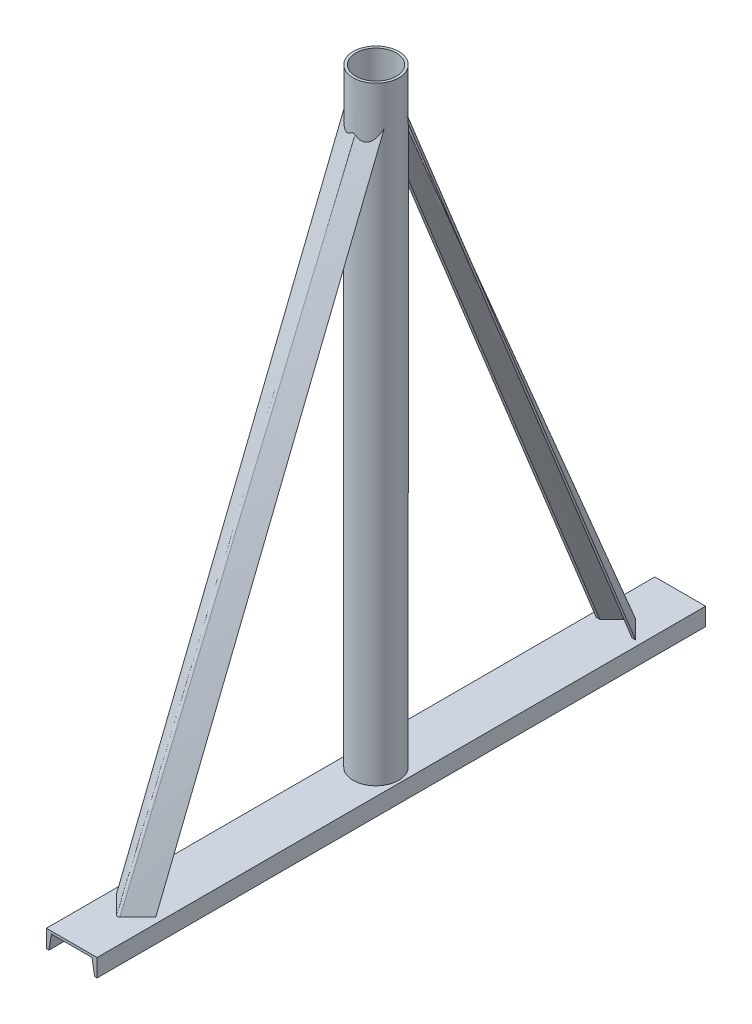
from build123d import *
from build123d.topology import SkipClean

# Parameters (mm, degrees)
BOSS_EXTRUDE1_DEPTH = 1524
SKETCH2_R           = 57.15
SKETCH2_R_2         = 50.8
BOSS_EXTRUDE2_DEPTH = 1524
SKETCH5_W           = 191.890592184
SKETCH5_H           = 1601.586805461
CUT_EXTRUDE1_DEPTH  = 826.77
SKETCH11_R          = 50.8
CUT_EXTRUDE3_DEPTH  = 826.77


with BuildPart() as part:
    # Sketch1 → Boss-Extrude1 (new body)
    with BuildSketch(Plane.XY):
        Polygon((63.5, 0), (-63.5, 0), (-63.5, -44.45), (-57.15, -44.45), (-50.8, -6.35), (50.8, -6.35), (57.15, -44.45), (63.5, -44.45), align=None)
    extrude(amount=BOSS_EXTRUDE1_DEPTH)

    # Sketch2 → Boss-Extrude2 (add)
    with BuildSketch(Plane(origin=(0, 0, 0), x_dir=(1, 0, 0), z_dir=(0, 1, 0))):
        with Locations(Location((0, -762, 0), (0, 0, 90))):
            Circle(SKETCH2_R)
        with Locations(Location((0, -762, 0), (0, 0, 270))):
            Circle(SKETCH2_R_2, mode=Mode.SUBTRACT)
    boss_extrude2 = extrude(amount=BOSS_EXTRUDE2_DEPTH)

    # Sketch5 → Cut-Extrude1 (cut)
    with BuildSketch(Plane.XY.offset(762)):
        with Locations((-8.264108144, 805.673812156)):
            Rectangle(SKETCH5_W, SKETCH5_H)
    extrude(amount=CUT_EXTRUDE1_DEPTH, mode=Mode.SUBTRACT)

    # Sketch8 for Loft6 → Loft6 section 0
    with BuildSketch(Plane.XY.offset(736.6)):
        with BuildLine():
            Line((4.490128061, 1477.690128061), (49.391408666, 1432.788847455))
            Line((49.391408666, 1432.788847455), (40.411152545, 1432.788847455))
            Line((40.411152545, 1432.788847455), (1.796051224, 1471.403948776))
            # circular arc as an exact rational Bezier (weights 1, cos(half-angle), 1)
            Bezier((1.796051224, 1471.403948776), (0, 1473.2), (-1.796051224, 1471.403948776), weights=[1, 0.707106781, 1])
            Line((-1.796051224, 1471.403948776), (-40.411152545, 1432.788847455))
            Line((-40.411152545, 1432.788847455), (-49.391408666, 1432.788847455))
            Line((-49.391408666, 1432.788847455), (-4.490128061, 1477.690128061))
            Bezier((-4.490128061, 1477.690128061), (0, 1482.180256121), (4.490128061, 1477.690128061), weights=[1, 0.707106781, 1])
        make_face()
    # Sketch4 for Loft6 → Loft6 section 1
    with BuildSketch(Plane(origin=(0, 0, 0), x_dir=(1, 0, 0), z_dir=(0, 1, 0))):
        with BuildLine():
            Line((4.490128061, -116.159871939), (49.391408666, -161.061152545))
            Line((49.391408666, -161.061152545), (40.411152545, -161.061152545))
            Line((40.411152545, -161.061152545), (1.796051224, -122.446051224))
            Bezier((1.796051224, -122.446051224), (0, -120.65), (-1.796051224, -122.446051224), weights=[1, 0.707106781, 1])
            Line((-1.796051224, -122.446051224), (-40.411152545, -161.061152545))
            Line((-40.411152545, -161.061152545), (-49.391408666, -161.061152545))
            Line((-49.391408666, -161.061152545), (-4.490128061, -116.159871939))
            Bezier((-4.490128061, -116.159871939), (0, -111.669743879), (4.490128061, -116.159871939), weights=[1, 0.707106781, 1])
        make_face()
    loft6 = loft()

    # Mirror1: Boss-Extrude2, Loft6 across plane
    with SkipClean():  # the faces are left unmerged after this step: merging them gives an invalid solid
        add(boss_extrude2.mirror(Plane.XY.offset(762)))
        add(loft6.mirror(Plane.XY.offset(762)))

    # Sketch11 → Cut-Extrude3 (cut)
    with SkipClean():  # the faces are left unmerged after this step: merging them gives an invalid solid
        with BuildSketch(Plane(origin=(0, 1549.4, 0), x_dir=(1, 0, 0), z_dir=(0, 1, 0))):
            with Locations(Location((0, -762, 0), (0, 0, 270))):
                Circle(SKETCH11_R)
        extrude(amount=-CUT_EXTRUDE3_DEPTH, mode=Mode.SUBTRACT)


solid = part.part
